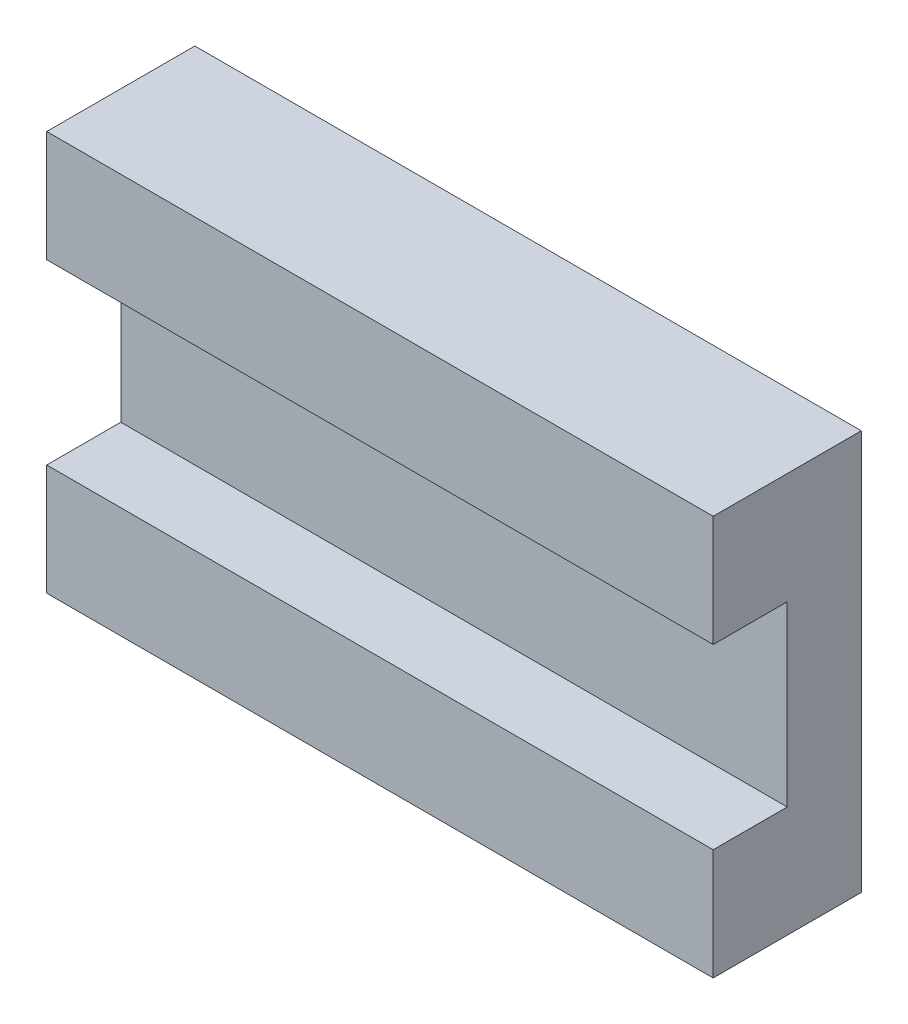
from build123d import *

# Parameters (mm, degrees)
SKETCH1_W           = 45
SKETCH1_H           = 27
BOSS_EXTRUDE1_DEPTH = 10
SKETCH1_3_R         = 1.5
CUT_EXTRUDE1_DEPTH  = 5
SKETCH2_W           = 45
SKETCH2_H           = 12
CUT_EXTRUDE2_DEPTH  = 5


with BuildPart() as part:
    # Sketch1 → Boss-Extrude1 (new body)
    with BuildSketch(Plane.XY):
        Rectangle(SKETCH1_W, SKETCH1_H)
    extrude(amount=BOSS_EXTRUDE1_DEPTH)

    # Sketch1_3 → Cut-Extrude1 (cut)
    with BuildSketch(Plane.XY):
        with Locations((-10, 10)):
            Circle(SKETCH1_3_R)
        with Locations((10, 10)):
            Circle(SKETCH1_3_R)
        with Locations((10, -10)):
            Circle(SKETCH1_3_R)
        with Locations((-10, -10)):
            Circle(SKETCH1_3_R)
    extrude(amount=CUT_EXTRUDE1_DEPTH, mode=Mode.SUBTRACT)

    # Sketch2 → Cut-Extrude2 (cut)
    with BuildSketch(Plane.XY.offset(10)):
        Rectangle(SKETCH2_W, SKETCH2_H)
    extrude(amount=-CUT_EXTRUDE2_DEPTH, mode=Mode.SUBTRACT)


solid = part.part
